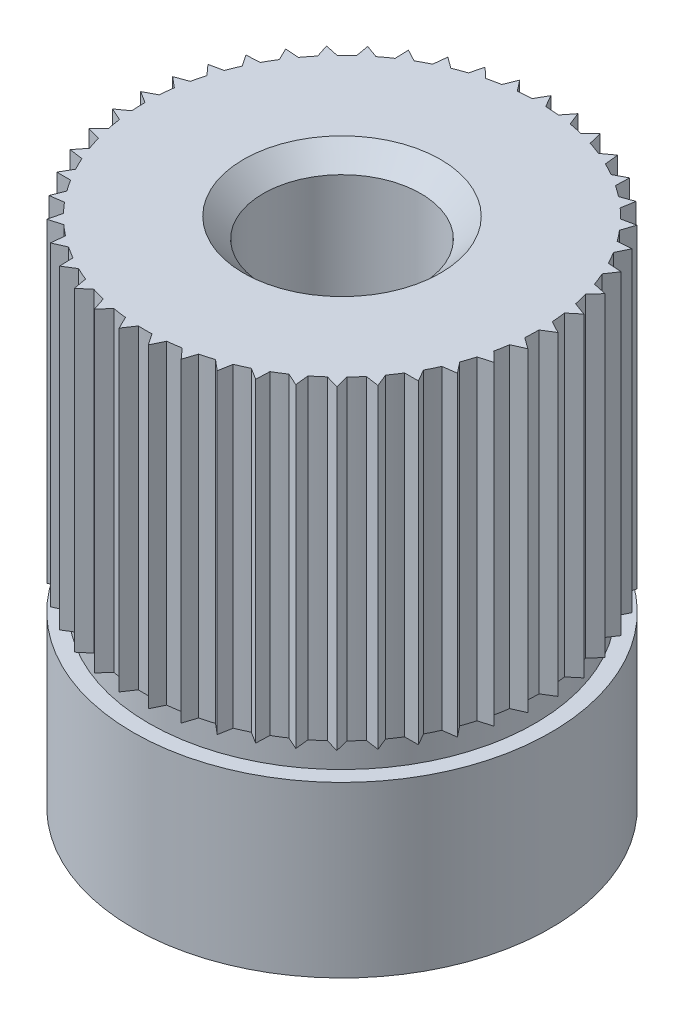
from build123d import *

# Parameters (mm, degrees)
SCHIZZO1_R                   = 2.65
ESTRUSIONE_ESTRUSIONE1_DEPTH = 2.15
SCHIZZO2_R                   = 2.55
ESTRUSIONE_ESTRUSIONE2_DEPTH = 0.35
ESTRUSIONE_ESTRUSIONE3_DEPTH = 4
SCHIZZO4_R                   = 2.5
ESTRUSIONE_ESTRUSIONE4_DEPTH = 4
RIPETIZIONECIRCOLARE1_COUNT  = 45
SCHIZZO5_R                   = 1
TAGLIO_ESTRUSIONE1_DEPTH     = 7.5
SMUSSO1_SIZE                 = 0.25
SCHIZZO6_R                   = 2.75
SCHIZZO6_R_2                 = 2.45
TAGLIO_ESTRUSIONE2_DEPTH     = 0.35


with BuildPart() as part:
    # Schizzo1 → Estrusione-Estrusione1 (new body)
    with BuildSketch(Plane(origin=(0, 0, 0), x_dir=(1, 0, 0), z_dir=(0, 1, 0))):
        Circle(SCHIZZO1_R)
    extrude(amount=ESTRUSIONE_ESTRUSIONE1_DEPTH)

    # Schizzo2 → Estrusione-Estrusione2 (add)
    with BuildSketch(Plane(origin=(0, 2.15, 0), x_dir=(1, 0, 0), z_dir=(0, 1, 0))):
        Circle(SCHIZZO2_R)
    extrude(amount=ESTRUSIONE_ESTRUSIONE2_DEPTH)

    # Schizzo3 → Estrusione-Estrusione3 (add)
    with BuildSketch(Plane(origin=(0, 2.5, 0), x_dir=(1, 0, 0), z_dir=(0, 1, 0))):
        with BuildLine():
            Line((0, 2.65), (-0.087486608, 2.49846875))
            ThreePointArc((-0.087486608, 2.49846875), (0, 2.5), (0.087486608, 2.49846875))
            Line((0.087486608, 2.49846875), (0, 2.65))
        make_face()
    estrusione_estrusione3 = extrude(amount=ESTRUSIONE_ESTRUSIONE3_DEPTH)

    # Schizzo4 → Estrusione-Estrusione4 (add)
    with BuildSketch(Plane(origin=(0, 2.5, 0), x_dir=(1, 0, 0), z_dir=(0, 1, 0))):
        Circle(SCHIZZO4_R)
    extrude(amount=ESTRUSIONE_ESTRUSIONE4_DEPTH)

    # RipetizioneCircolare1: Estrusione-Estrusione3 ×45 about axis
    ripetizionecircolare1_axis = Axis((0, 0, 0), (0, 1, 0))
    for i in range(1, RIPETIZIONECIRCOLARE1_COUNT):
        add(estrusione_estrusione3.rotate(ripetizionecircolare1_axis, i * 360 / RIPETIZIONECIRCOLARE1_COUNT))

    # Schizzo5 → Taglio-Estrusione1 (cut, through all)
    with BuildSketch(Plane(origin=(0, 6.5, 0), x_dir=(1, 0, 0), z_dir=(0, 1, 0))):
        Circle(SCHIZZO5_R)
    extrude(amount=-TAGLIO_ESTRUSIONE1_DEPTH, mode=Mode.SUBTRACT)

    # Smusso1
    smusso1_edges = [part.edges().sort_by_distance(p)[0] for p in [
        (-1, 6.5, 0),
    ]]
    chamfer(smusso1_edges, length=SMUSSO1_SIZE)

    # Schizzo6 → Taglio-Estrusione2 (cut)
    with BuildSketch(Plane(origin=(0, 2.15, 0), x_dir=(1, 0, 0), z_dir=(0, 1, 0))):
        Circle(SCHIZZO6_R)
        Circle(SCHIZZO6_R_2, mode=Mode.SUBTRACT)
    extrude(amount=TAGLIO_ESTRUSIONE2_DEPTH, mode=Mode.SUBTRACT)


solid = part.part
